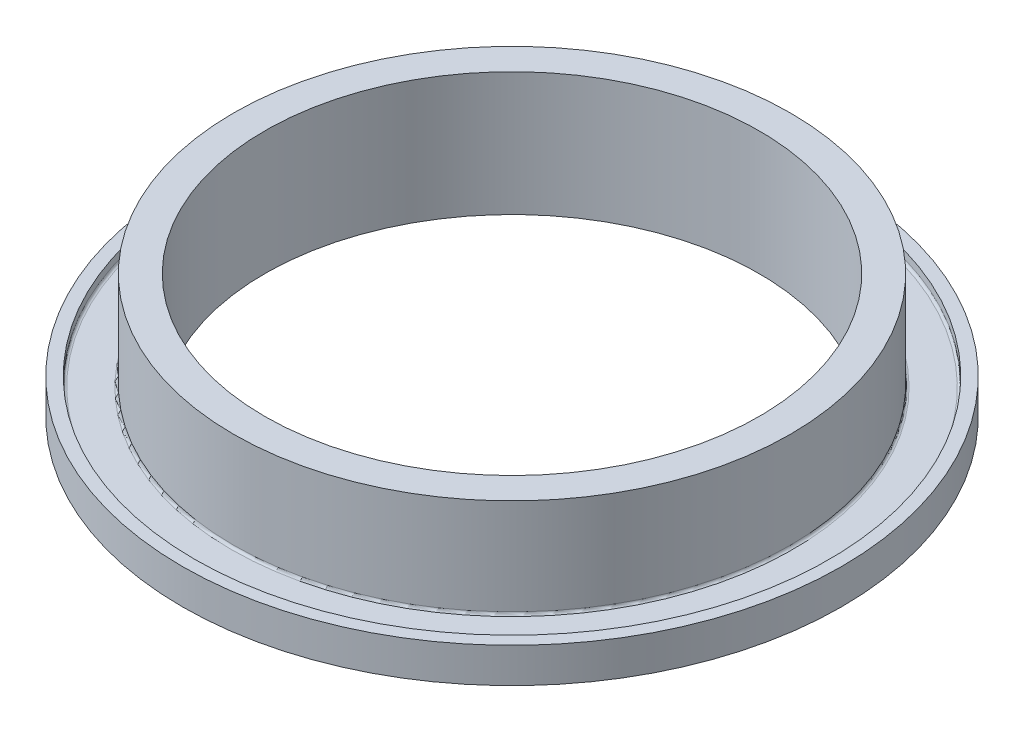
from build123d import *

# Parameters (mm, degrees)
SKETCH1_R           = 57.15
SKETCH1_R_2         = 50.7746
BOSS_EXTRUDE1_DEPTH = 25.4
FILLET1_R           = 0.5


with BuildPart() as part:
    # Sketch1 → Boss-Extrude1 (new body)
    with BuildSketch(Plane(origin=(0, 0, 0), x_dir=(1, 0, 0), z_dir=(0, 1, 0))):
        Circle(SKETCH1_R)
        Circle(SKETCH1_R_2, mode=Mode.SUBTRACT)
    extrude(amount=BOSS_EXTRUDE1_DEPTH)

    # Sketch2 → Revolve1 (revolve)
    with BuildSketch(Plane.XY):
        Polygon((-57.15, 5.175), (-65.15, 5.175), (-65.15, 7.175), (-67.69, 7.175), (-67.69, 0), (-65.15, 0), (-65.15, 2), (-57.15, 2), align=None)
    revolve(axis=Axis((0, 25.4, 0), (0, -1, 0)))

    # Fillet1
    fillet1_edges = [part.edges().sort_by_distance(p)[0] for p in [
        (-57.15, 5.175, 0),
        (-57.15, 2, 0),
        (65.15, 2, 0),
        (65.15, 5.175, 0),
    ]]
    fillet(fillet1_edges, radius=FILLET1_R)


solid = part.part
